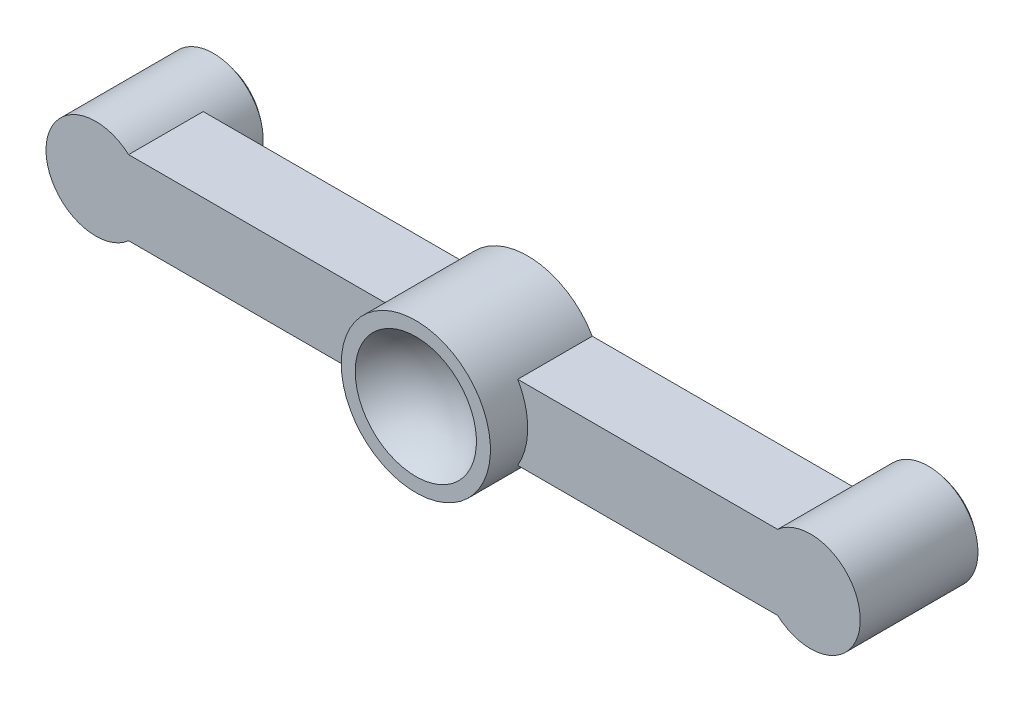
from build123d import *

# Parameters (mm, degrees)
SKETCH_1_R      = 8
SKETCH_1_R_2    = 12
SKETCH_1_W      = 115
SKETCH_1_H      = 12
EXTRUDE_1_DEPTH = 12


with BuildPart() as part:
    # 草图1 → 凸台-拉伸1 (new body)
    with BuildSketch(Plane.XY):
        with Locations((115, 0)):
            Circle(SKETCH_1_R)
        Circle(SKETCH_1_R)
        with Locations((57.5, 0)):
            Circle(SKETCH_1_R_2)
        with Locations((57.5, 0)):
            Rectangle(SKETCH_1_W, SKETCH_1_H)
    extrude(amount=EXTRUDE_1_DEPTH)

    # 草图2 → 旋转2 (revolve)
    with BuildSketch(Plane(origin=(0, 0, 0), x_dir=(1, 0, 0), z_dir=(0, 1, 0))):
        with BuildLine():
            ThreePointArc((-8, 6.94427191), (-4.281865077, 9.210068308), (0, 10))
            Line((0, 10), (0, 0))
            Line((0, 0), (-8, 0))
            Line((-8, 0), (-8, 6.94427191))
        make_face()
    revolve_2 = revolve(axis=Axis((0, 0, -10), (0, 0, 1)))

    # 镜向1: 旋转2 across plane
    add(revolve_2.mirror(Plane(origin=(57.5, 0, 0), x_dir=(0, 0, 1), z_dir=(1, 0, 0))))

    # 草图3 → 旋转3 (revolve)
    with BuildSketch(Plane(origin=(0, 0, 0), x_dir=(1, 0, 0), z_dir=(0, 1, 0))):
        with BuildLine():
            Line((57.5, -12), (57.5, -13))
            ThreePointArc((57.5, -13), (52.022774425, -14.322921748), (47.753205655, -18))
            Line((47.753205655, -18), (45.5, -18))
            Line((45.5, -18), (45.5, -12))
            Line((45.5, -12), (57.5, -12))
        make_face()
    revolve(axis=Axis((57.5, 0, 12), (0, 0, 1)))


solid = part.part
